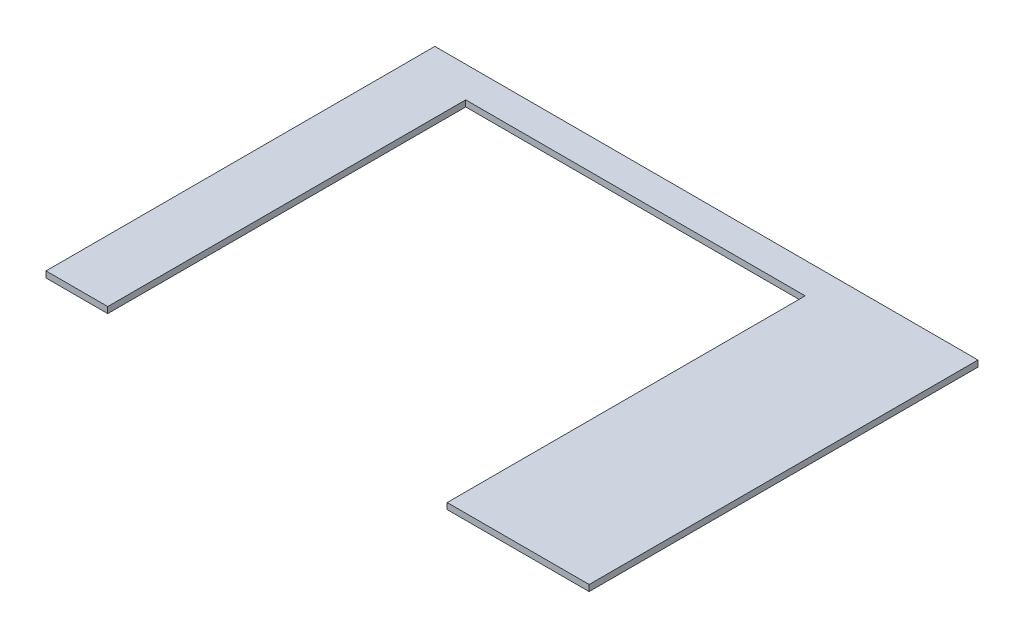
from build123d import *

# Parameters (mm, degrees)
EXTRUDE_1_DEPTH = 10


with BuildPart() as part:
    # Эскиз1 → Бобышка-Вытянуть1 (new body)
    with BuildSketch(Plane(origin=(0, 0, 0), x_dir=(1, 0, 0), z_dir=(0, 1, 0))):
        Polygon((100, 0), (100, 580), (650, 580), (650, 0), (880, 0), (880, 630), (0, 630), (0, 0), align=None)
    extrude(amount=EXTRUDE_1_DEPTH)


solid = part.part
